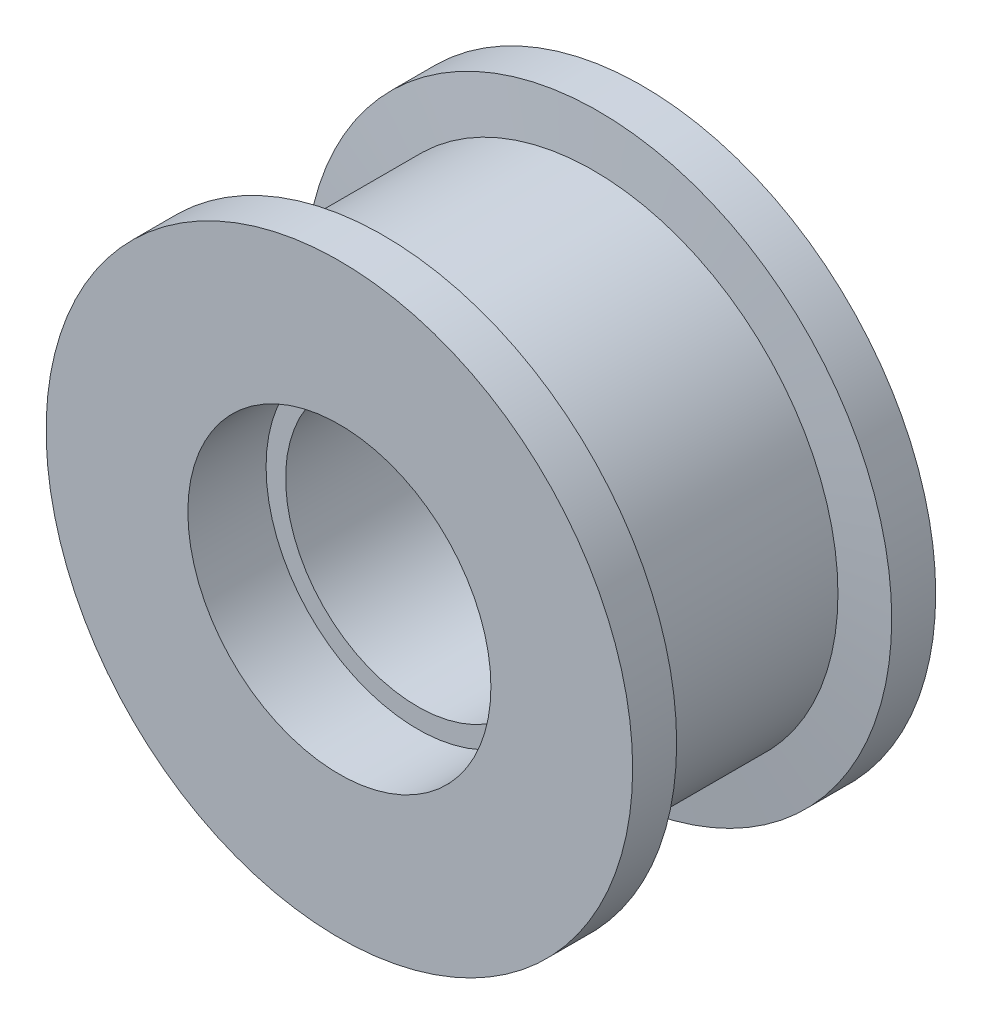
from build123d import *


with BuildPart() as part:
    # 草图2 → 旋转2 (revolve)
    with BuildSketch(Plane(origin=(0, 0, 0), x_dir=(0, 0, -1), z_dir=(1, 0, 0))):
        Polygon((-4202.915240979, -7473.983238222), (-4193.915240979, -7473.983238222), (-4192.915240979, -7463.983238222), (-4150.915240979, -7463.983238222), (-4149.915240979, -7473.983238222), (-4140.915240979, -7473.983238222), (-4140.915240979, -7444.983238222), (-4156.915240979, -7444.983238222), (-4156.915240979, -7440.983238222), (-4186.915240979, -7440.983238222), (-4186.915240979, -7444.983238222), (-4202.915240979, -7444.983238222), align=None)
    revolve(axis=Axis((0, -7413.983238222, 4235.178380328), (0, 0, -1)))


solid = part.part
